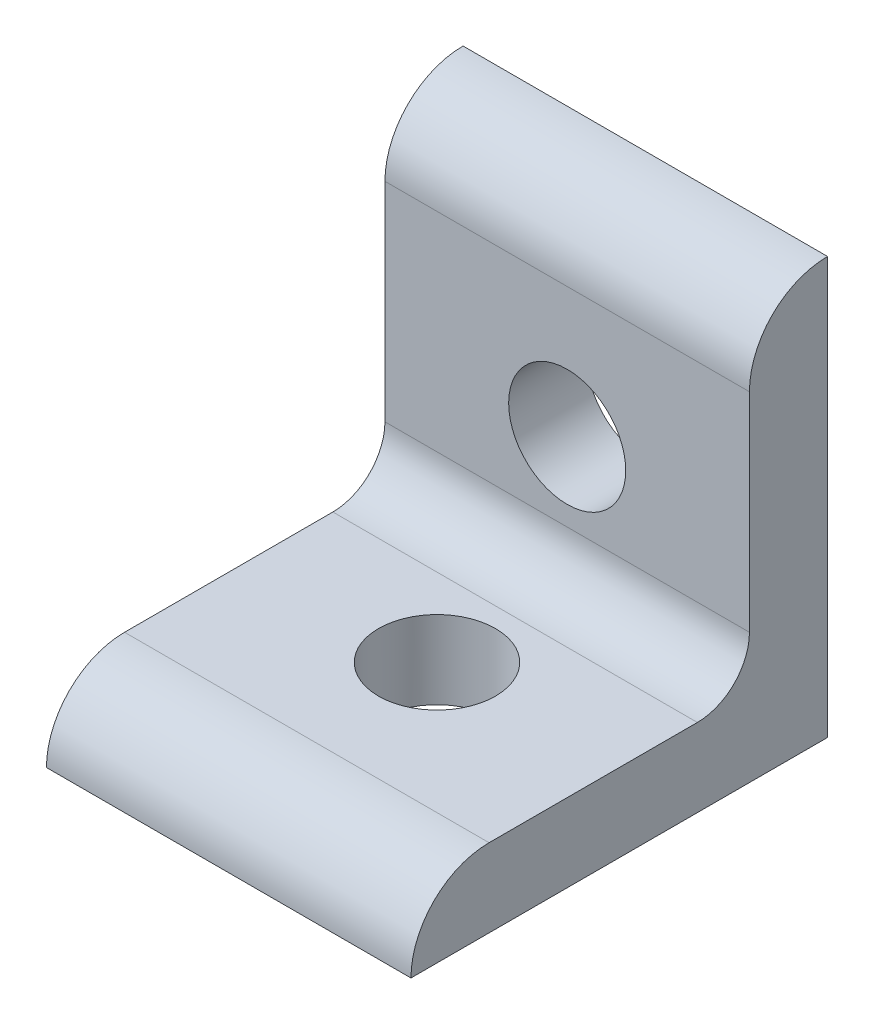
from build123d import *

# Parameters (mm, degrees)
BOSS_EXTRUDE1_DEPTH = 11.1125
SKETCH6_R           = 3.5687
CUT_EXTRUDE1_DEPTH  = 7.62
SKETCH7_R           = 3.5687
CUT_EXTRUDE2_DEPTH  = 7.62


with BuildPart() as part:
    # Sketch1 → Boss-Extrude1 (new body, symmetric)
    with BuildSketch(Plane(origin=(0, -22.225, 0), x_dir=(0, -1, 0), z_dir=(-1, 0, 0))):
        with BuildLine():
            Line((0, 0), (0, 25.4))
            ThreePointArc((0, 25.4), (-3.367596045, 24.005096045), (-4.7625, 20.6375))
            Line((-4.7625, 20.6375), (-4.7625, 7.9375))
            ThreePointArc((-4.7625, 7.9375), (-5.69243597, 5.69243597), (-7.9375, 4.7625))
            Line((-7.9375, 4.7625), (-20.6375, 4.7625))
            ThreePointArc((-20.6375, 4.7625), (-24.005096045, 3.367596045), (-25.4, 0))
            Line((-25.4, 0), (0, 0))
        make_face()
    extrude(amount=BOSS_EXTRUDE1_DEPTH, both=True)

    # Sketch6 → Cut-Extrude1 (cut)
    with BuildSketch(Plane(origin=(0, -22.225, 0), x_dir=(-1, 0, 0), z_dir=(0, -1, 0))):
        with Locations((0, -12.7)):
            Circle(SKETCH6_R)
    extrude(amount=-CUT_EXTRUDE1_DEPTH, mode=Mode.SUBTRACT)

    # Sketch7 → Cut-Extrude2 (cut)
    with BuildSketch(Plane(origin=(0, 0, 0), x_dir=(-1, 0, 0), z_dir=(0, 0, -1))):
        with Locations((0, -9.525)):
            Circle(SKETCH7_R)
    extrude(amount=-CUT_EXTRUDE2_DEPTH, mode=Mode.SUBTRACT)


solid = part.part
